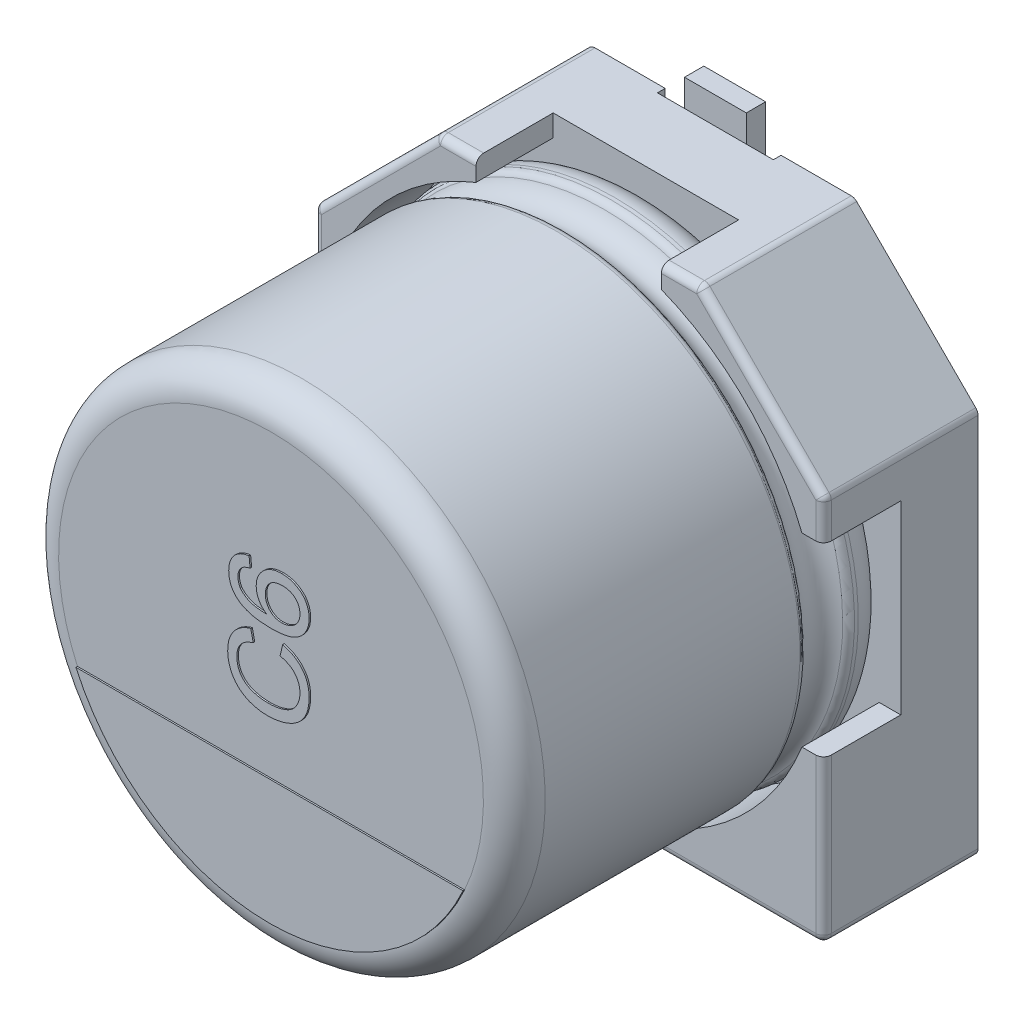
from build123d import *

# Parameters (mm, degrees)
BOSS_EXTRUDE1_DEPTH = 1
BOSS_EXTRUDE2_DEPTH = 1
SKETCH7_R           = 0.35
BOSS_EXTRUDE3_DEPTH = 0.15
SKETCH9_W           = 1.5
SKETCH9_H           = 2.35
CUT_EXTRUDE1_DEPTH  = 0.1
FILLET1_R           = 0.1
FILLET2_R           = 0.1
BOSS_EXTRUDE4_DEPTH = 0.02
TEXT_2_DEPTH        = 0.02
SKETCH19_W          = 0.8
SKETCH19_H          = 2.6
BOSS_EXTRUDE6_DEPTH = 0.25


with BuildPart() as part:
    # Sketch2 → Boss-Extrude1 (new body)
    with BuildSketch(Plane.XY):
        Polygon((-3.3, 1.7), (-1.7, 3.3), (1.7, 3.3), (3.3, 1.7), (3.3, -3.3), (-3.3, -3.3), align=None)
    extrude(amount=BOSS_EXTRUDE1_DEPTH)

    # Sketch4 → Boss-Extrude2 (add)
    with BuildSketch(Plane.XY.offset(1)):
        with BuildLine():
            Line((-3.3, 1.7), (-1.7, 3.3))
            Line((-1.7, 3.3), (-1.2, 3.3))
            Line((-1.2, 3.3), (-1.2, 3.020347662))
            ThreePointArc((-1.2, 3.020347662), (-2.298097039, 2.298097039), (-3.020347662, 1.2))
            Line((-3.020347662, 1.2), (-3.3, 1.2))
            Line((-3.3, 1.2), (-3.3, 1.7))
        make_face()
        with BuildLine():
            Line((1.7, 3.3), (3.3, 1.7))
            Line((3.3, 1.7), (3.3, 1.2))
            Line((3.3, 1.2), (3.020347662, 1.2))
            ThreePointArc((3.020347662, 1.2), (2.298097039, 2.298097039), (1.2, 3.020347662))
            Line((1.2, 3.020347662), (1.2, 3.3))
            Line((1.2, 3.3), (1.7, 3.3))
        make_face()
        with BuildLine():
            Line((3.3, -1.2), (3.3, -3.3))
            Line((3.3, -3.3), (1.2, -3.3))
            Line((1.2, -3.3), (1.2, -3.020347662))
            ThreePointArc((1.2, -3.020347662), (2.298097039, -2.298097039), (3.020347662, -1.2))
            Line((3.020347662, -1.2), (3.3, -1.2))
        make_face()
        with BuildLine():
            Line((-3.3, -1.2), (-3.3, -3.3))
            Line((-3.3, -3.3), (-1.2, -3.3))
            Line((-1.2, -3.3), (-1.2, -3.020347662))
            ThreePointArc((-1.2, -3.020347662), (-2.298097039, -2.298097039), (-3.020347662, -1.2))
            Line((-3.020347662, -1.2), (-3.3, -1.2))
        make_face()
    extrude(amount=BOSS_EXTRUDE2_DEPTH)

    # Sketch7 → Boss-Extrude3 (add)
    with BuildSketch(Plane(origin=(0, 0, 0), x_dir=(1, 0, 0), z_dir=(0, 0, -1))):
        with Locations((-2.232271432, 1.911844843)):
            Circle(SKETCH7_R)
        with Locations((2.232271432, 1.911844843)):
            Circle(SKETCH7_R)
        with Locations((-2.232271432, -1.911844843)):
            Circle(SKETCH7_R)
        with Locations((2.232271432, -1.911844843)):
            Circle(SKETCH7_R)
    extrude(amount=BOSS_EXTRUDE3_DEPTH)

    # Sketch9 → Cut-Extrude1 (cut)
    with BuildSketch(Plane(origin=(0, 0, 0), x_dir=(1, 0, 0), z_dir=(0, 0, -1))):
        with Locations((0, 2.125)):
            Rectangle(SKETCH9_W, SKETCH9_H)
        with Locations((0, -2.125)):
            Rectangle(SKETCH9_W, SKETCH9_H)
    extrude(amount=-CUT_EXTRUDE1_DEPTH, mode=Mode.SUBTRACT)

    # Fillet1
    fillet1_edges = [part.edges().sort_by_distance(p)[0] for p in [
        (3.3, -3.3, 1),
        (-3.3, -3.3, 1),
        (-3.3, 1.7, 1),
        (-1.7, 3.3, 1),
        (1.7, 3.3, 1),
        (3.3, 1.7, 1),
    ]]
    fillet(fillet1_edges, radius=FILLET1_R)

    # Sketch10 → Revolve1 (revolve)
    with BuildSketch(Plane(origin=(0, 0, 0), x_dir=(0, 0, -1), z_dir=(1, 0, 0))):
        with BuildLine():
            Line((-5.853626625, 0), (-1, 0))
            Line((-1, 0), (-1, 2.75))
            ThreePointArc((-1, 2.75), (-1.117157288, 3.032842712), (-1.4, 3.15))
            Line((-1.4, 3.15), (-1.449422929, 3.15))
            ThreePointArc((-1.449422929, 3.15), (-1.504479696, 3.133479053), (-1.541344666, 3.089375046))
            ThreePointArc((-1.541344666, 3.089375046), (-1.801990181, 2.917472047), (-2.062635697, 3.089375046))
            ThreePointArc((-2.062635697, 3.089375046), (-2.099500666, 3.133479053), (-2.154557434, 3.15))
            Line((-2.154557434, 3.15), (-5.453626625, 3.15))
            ThreePointArc((-5.453626625, 3.15), (-5.736469337, 3.032842712), (-5.853626625, 2.75))
            Line((-5.853626625, 2.75), (-5.853626625, 0))
        make_face()
    revolve(axis=Axis((0, 0, -18.9630778), (0, 0, 1)))

    # Fillet2
    fillet2_edges = [part.edges().sort_by_distance(p)[0] for p in [
        (2.2, -3.3, 2),
        (3.270710678, -3.270710678, 2),
        (3.3, 1.429289322, 2),
        (3.292387953, 1.696846987, 2),
        (1.429289322, 3.3, 2),
        (1.696846987, 3.292387953, 2),
        (-1.429289322, 3.3, 2),
        (-1.696846987, 3.292387953, 2),
        (-2.5, 2.5, 2),
        (-3.292387953, 1.696846987, 2),
        (-3.3, -2.2, 2),
        (-3.270710678, -3.270710678, 2),
        (3.3, -2.2, 2),
        (2.5, 2.5, 2),
        (-3.3, 1.429289322, 2),
        (-2.2, -3.3, 2),
    ]]
    fillet(fillet2_edges, radius=FILLET2_R)

    # Sketch13 → Boss-Extrude4 (add)
    with BuildSketch(Plane.XY.offset(5.853626625)):
        with BuildLine():
            Line((-2.506238836, -1.131930607), (2.506238836, -1.131930607))
            ThreePointArc((2.506238836, -1.131930607), (0, -2.75), (-2.506238836, -1.131930607))
        make_face()
    extrude(amount=BOSS_EXTRUDE4_DEPTH)

    # Sketch15 → Text 2 (add)
    with BuildSketch(Plane.XY.offset(5.853626625)):
        with BuildLine():
            Line((0.137389622, 0.316593633), (0.171139963, 0.461473149))
            add(Edge.make_bspline(
                [(0.171139963, 0.461473149), (0.184719205, 0.457843617), (0.211281888, 0.450743802), (0.249294555, 0.436704736), (0.284973396, 0.420954535), (0.318198658, 0.403080099), (0.348825876, 0.383025378), (0.37700883, 0.360877976), (0.402792333, 0.336641169), (0.425858287, 0.31012897), (0.446489175, 0.282031663), (0.464171898, 0.252152583), (0.479591278, 0.221021834), (0.491950748, 0.188130242), (0.501325327, 0.153719305), (0.508136304, 0.117874786), (0.512336792, 0.080509598), (0.512889354, 0.055039538), (0.513170865, 0.042063415)],
                knots=[0, 0, 0, 0, 1.145367768, 2.240481511, 3.299486216, 4.322926322, 5.312543435, 6.280301985, 7.2416403, 8.192823262, 9.141388579, 10.079393599, 11.019812878, 11.970222822, 12.938950422, 13.923894909, 14.942295558, 16, 16, 16, 16], degree=3))
            add(Edge.make_bspline(
                [(0.513170865, 0.042063415), (0.512974968, 0.028750287), (0.512591712, 0.002704216), (0.509548347, -0.035461334), (0.50408886, -0.071710574), (0.497105361, -0.106172698), (0.487517876, -0.138603304), (0.476080502, -0.169237106), (0.462232577, -0.197809744), (0.446522059, -0.224623591), (0.428664346, -0.249552903), (0.409152567, -0.273167676), (0.387446592, -0.294893809), (0.364059715, -0.315274756), (0.338683214, -0.333866555), (0.311661899, -0.351353217), (0.282519639, -0.366881226), (0.251796737, -0.381026037), (0.219790643, -0.393441241), (0.187133568, -0.404424353), (0.153760439, -0.413403647), (0.119952084, -0.421134241), (0.085424029, -0.426750142), (0.050435341, -0.431208994), (0.014771509, -0.433660561), (-0.009201459, -0.433983161), (-0.021278143, -0.434145675)],
                knots=[0, 0, 0, 0, 1.180680974, 2.309907975, 3.39230657, 4.430402719, 5.425739985, 6.38846843, 7.327253855, 8.238163682, 9.141319901, 10.044148192, 10.951882972, 11.861898394, 12.79276478, 13.739539846, 14.714057202, 15.718574761, 16.737652364, 17.7573291, 18.772768038, 19.801551793, 20.831755737, 21.873891013, 22.928945814, 24, 24, 24, 24], degree=3))
            add(Edge.make_bspline(
                [(-0.021278143, -0.434145675), (-0.034315397, -0.4339132), (-0.060073717, -0.433453889), (-0.098081116, -0.430862244), (-0.134761949, -0.426098769), (-0.17014477, -0.419495443), (-0.204305873, -0.411082573), (-0.23725329, -0.400840529), (-0.268852986, -0.388622281), (-0.299113504, -0.374745627), (-0.327665253, -0.358785546), (-0.354762577, -0.3416054), (-0.379878011, -0.322520006), (-0.403474105, -0.302187934), (-0.425149261, -0.280085417), (-0.444954877, -0.256284136), (-0.463070995, -0.230988325), (-0.479329594, -0.204201975), (-0.493595656, -0.176275134), (-0.506302564, -0.147622628), (-0.516717602, -0.118130488), (-0.525377287, -0.088032537), (-0.532271201, -0.057263976), (-0.536881183, -0.025752912), (-0.539885404, 0.006471539), (-0.540292549, 0.02819978), (-0.540498339, 0.039182288)],
                knots=[0, 0, 0, 0, 1.185610122, 2.34246615, 3.46204209, 4.547238403, 5.613845268, 6.659506797, 7.682407252, 8.692734231, 9.683951048, 10.654680354, 11.607833779, 12.549673105, 13.484816388, 14.419272854, 15.362680812, 16.31159957, 17.265732262, 18.21261905, 19.159670199, 20.10733745, 21.059306249, 22.024427552, 23.00144979, 24, 24, 24, 24], degree=3))
            add(Edge.make_bspline(
                [(-0.540498339, 0.039182288), (-0.54027585, 0.051472155), (-0.539838527, 0.075629106), (-0.53596558, 0.111030265), (-0.53016218, 0.145076857), (-0.521400985, 0.17750367), (-0.510653256, 0.208616176), (-0.496791219, 0.237924274), (-0.481084534, 0.266024209), (-0.462639265, 0.292395393), (-0.442059798, 0.317116672), (-0.419396701, 0.339965227), (-0.394799964, 0.360899322), (-0.368077184, 0.379659831), (-0.339408707, 0.396504218), (-0.308850674, 0.411613497), (-0.276208278, 0.424627676), (-0.253468798, 0.431587541), (-0.241890133, 0.435131419)],
                knots=[0, 0, 0, 0, 1.098215313, 2.158650937, 3.179873416, 4.182349117, 5.157851008, 6.118027029, 7.076341197, 8.032298369, 8.990121974, 9.948357669, 10.905435138, 11.873450097, 12.863034414, 13.874936208, 14.917943528, 16, 16, 16, 16], degree=3))
            Line((-0.241890133, 0.435131419), (-0.210815123, 0.290251903))
            add(Edge.make_bspline(
                [(-0.210815123, 0.290251903), (-0.21970095, 0.287406696), (-0.237093262, 0.281837744), (-0.261880399, 0.271949526), (-0.284890959, 0.26127058), (-0.305968529, 0.249546525), (-0.325118157, 0.236751953), (-0.342572578, 0.223181488), (-0.358006003, 0.208509995), (-0.371774287, 0.193035906), (-0.383503548, 0.176359634), (-0.393897604, 0.158872143), (-0.402497099, 0.140204709), (-0.409770496, 0.120625878), (-0.415306335, 0.099952647), (-0.419201016, 0.078269202), (-0.421455067, 0.05555649), (-0.421789822, 0.040079052), (-0.421960554, 0.032185266)],
                knots=[0, 0, 0, 0, 1.235697765, 2.418642872, 3.532555292, 4.594392283, 5.610119701, 6.580908344, 7.519430642, 8.427315627, 9.319973334, 10.216139639, 11.118687699, 12.038725643, 12.980015607, 13.949697744, 14.954307006, 16, 16, 16, 16], degree=3))
            add(Edge.make_bspline(
                [(-0.421960554, 0.032185266), (-0.42182894, 0.023122531), (-0.421570094, 0.005298806), (-0.418741414, -0.020887312), (-0.414566199, -0.046031584), (-0.408336958, -0.06996279), (-0.400471327, -0.092727501), (-0.391074044, -0.1144289), (-0.379637086, -0.134923416), (-0.366527285, -0.154190234), (-0.351810113, -0.172119905), (-0.335998775, -0.188775555), (-0.319056253, -0.204115277), (-0.300881808, -0.217955028), (-0.281409051, -0.230297385), (-0.260823414, -0.241466755), (-0.238987177, -0.251110914), (-0.208358467, -0.262011565), (-0.168833348, -0.2727293), (-0.120495718, -0.282252213), (-0.071437696, -0.288256875), (-0.038444502, -0.28892902), (-0.021895528, -0.289266159)],
                knots=[0, 0, 0, 0, 0.935100075, 1.839065892, 2.715632844, 3.564034634, 4.388093667, 5.199800233, 6.00171917, 6.806945003, 7.602082793, 8.393428172, 9.17553264, 9.958694158, 10.748327009, 11.553054559, 12.374096334, 13.209545573, 14.906836637, 16.595465087, 18.292327764, 20, 20, 20, 20], degree=3))
            add(Edge.make_bspline(
                [(-0.021895528, -0.289266159), (-0.001088295, -0.28888169), (0.039347759, -0.288134525), (0.097860474, -0.280941105), (0.152411861, -0.269796756), (0.194923463, -0.256480088), (0.226325575, -0.243084208), (0.248317261, -0.232252213), (0.268667217, -0.219887416), (0.287491124, -0.206297945), (0.304734045, -0.191308606), (0.320487583, -0.175128268), (0.334903322, -0.157753307), (0.347306436, -0.138977849), (0.35831932, -0.119524584), (0.368112186, -0.099638997), (0.376394559, -0.079308568), (0.382828475, -0.058451271), (0.388388272, -0.03736), (0.392020193, -0.015802455), (0.394069935, 0.006215216), (0.39444386, 0.020999538), (0.39463308, 0.02848096)],
                knots=[0, 0, 0, 0, 2.106854985, 4.094388766, 5.961441423, 7.741458329, 8.594569961, 9.418076185, 10.222480919, 11.003619353, 11.767127393, 12.533696482, 13.289066307, 14.050325982, 14.809648647, 15.552384038, 16.294338903, 17.030544626, 17.761979889, 18.502240791, 19.242077596, 20, 20, 20, 20], degree=3))
            add(Edge.make_bspline(
                [(0.39463308, 0.02848096), (0.39444584, 0.037409013), (0.394075974, 0.055045074), (0.390838523, 0.080901779), (0.386067714, 0.105827286), (0.378705874, 0.129519626), (0.369692165, 0.152297488), (0.358576684, 0.173974247), (0.345208005, 0.194481731), (0.330029126, 0.214061155), (0.312758155, 0.232351457), (0.293534236, 0.249113535), (0.27226973, 0.264151013), (0.249305901, 0.278094539), (0.223956735, 0.289809664), (0.196977778, 0.300660635), (0.167925608, 0.309702449), (0.147714502, 0.314263574), (0.137389622, 0.316593633)],
                knots=[0, 0, 0, 0, 1.013374089, 2.001772144, 2.95501459, 3.891367103, 4.814208647, 5.733921849, 6.652182523, 7.590185968, 8.54346024, 9.504121027, 10.481158517, 11.497760682, 12.549996529, 13.647863555, 14.798406869, 16, 16, 16, 16], degree=3))
        make_face()
        with BuildLine():
            Line((-0.263910173, 1.238554187), (-0.250739308, 1.106845536))
            add(Edge.make_bspline(
                [(-0.250739308, 1.106845536), (-0.262066955, 1.104003369), (-0.283389506, 1.098653428), (-0.31231033, 1.087434651), (-0.336772429, 1.075071798), (-0.349944593, 1.064331166), (-0.356106228, 1.059306945)],
                knots=[0, 0, 0, 0, 1.199207122, 2.257322842, 3.184815751, 4, 4, 4, 4], degree=3))
            add(Edge.make_bspline(
                [(-0.356106228, 1.059306945), (-0.360308802, 1.054994236), (-0.368574291, 1.046512136), (-0.379348416, 1.032587615), (-0.388476794, 1.017908865), (-0.395872165, 1.00243152), (-0.401714084, 0.986239198), (-0.405800816, 0.969264824), (-0.408330736, 0.951546855), (-0.408635402, 0.939474271), (-0.408789689, 0.933360548)],
                knots=[0, 0, 0, 0, 1.028360939, 2.022547923, 3.001693811, 3.976902288, 4.948369586, 5.937776631, 6.955661634, 8, 8, 8, 8], degree=3))
            add(Edge.make_bspline(
                [(-0.408789689, 0.933360548), (-0.408470554, 0.923449151), (-0.407839958, 0.903864664), (-0.401666469, 0.875130722), (-0.392426858, 0.847221986), (-0.383060608, 0.829931493), (-0.378332063, 0.8212024)],
                knots=[0, 0, 0, 0, 1.010336883, 1.996381556, 2.988474728, 4, 4, 4, 4], degree=3))
            add(Edge.make_bspline(
                [(-0.378332063, 0.8212024), (-0.371220994, 0.812615832), (-0.35662367, 0.794989661), (-0.329665846, 0.77206344), (-0.298406295, 0.751381043), (-0.269070379, 0.736194503), (-0.242664987, 0.7256364), (-0.220084591, 0.718679246), (-0.195186335, 0.71279144), (-0.167978967, 0.707874614), (-0.138433528, 0.704075164), (-0.106533319, 0.700898509), (-0.072196841, 0.699141789), (-0.048513373, 0.69875049), (-0.036301161, 0.69854872)],
                knots=[0, 0, 0, 0, 1.063250814, 2.182599524, 3.36380985, 4.638540699, 5.329632219, 6.077757597, 6.893023137, 7.772089793, 8.717285182, 9.73761699, 10.83341823, 12, 12, 12, 12], degree=3))
            add(Edge.make_bspline(
                [(-0.036301161, 0.69854872), (-0.047211061, 0.706313772), (-0.068567854, 0.721514335), (-0.096501329, 0.74833009), (-0.120124585, 0.77760857), (-0.138947726, 0.809396623), (-0.153668192, 0.842795113), (-0.163762394, 0.877283311), (-0.170639914, 0.912440761), (-0.171354352, 0.936208952), (-0.171714118, 0.948177771)],
                knots=[0, 0, 0, 0, 1.084001636, 2.121999332, 3.126469213, 4.123683166, 5.106931922, 6.075998312, 7.03114091, 8, 8, 8, 8], degree=3))
            add(Edge.make_bspline(
                [(-0.171714118, 0.948177771), (-0.171436912, 0.958480828), (-0.170889239, 0.978836477), (-0.166549178, 1.008812469), (-0.158958131, 1.037550632), (-0.149068989, 1.065299905), (-0.13556661, 1.091527432), (-0.119785478, 1.116871804), (-0.100584882, 1.140751828), (-0.078998478, 1.1634471), (-0.055003426, 1.184214016), (-0.029048993, 1.202305372), (-0.001458965, 1.217752742), (0.027936119, 1.230034553), (0.059003446, 1.239766995), (0.091724958, 1.24671395), (0.126168435, 1.250895647), (0.149656836, 1.251444342), (0.161673404, 1.251725052)],
                knots=[0, 0, 0, 0, 0.981582189, 1.939302258, 2.87789191, 3.810544529, 4.740168451, 5.683209003, 6.65100384, 7.654285831, 8.664634098, 9.669256765, 10.664156186, 11.671836555, 12.699357328, 13.762200315, 14.855150938, 16, 16, 16, 16], degree=3))
            add(Edge.make_bspline(
                [(0.161673404, 1.251725052), (0.177551784, 1.251205655), (0.208955034, 1.250178424), (0.255125626, 1.242147114), (0.299579783, 1.22895578), (0.334753634, 1.213359264), (0.361740804, 1.198980582), (0.380617593, 1.186774631), (0.398356819, 1.173722225), (0.415202853, 1.160071554), (0.430384613, 1.144832272), (0.444617472, 1.128928337), (0.457409357, 1.111834045), (0.469185898, 1.094052164), (0.479397361, 1.07524678), (0.488471349, 1.055965078), (0.496200717, 1.036048336), (0.502269576, 1.015432243), (0.507290467, 0.994222385), (0.510742792, 0.972348167), (0.512871929, 0.949867156), (0.513070448, 0.934668725), (0.513170865, 0.92698091)],
                knots=[0, 0, 0, 0, 1.777960384, 3.516337103, 5.232817765, 6.960340972, 7.816514579, 8.656393217, 9.475627613, 10.283429005, 11.082224935, 11.882498067, 12.672484914, 13.471761235, 14.269669532, 15.067244712, 15.857866702, 16.660166545, 17.47288749, 18.29786845, 19.139011754, 20, 20, 20, 20], degree=3))
            add(Edge.make_bspline(
                [(0.513170865, 0.92698091), (0.512810832, 0.91399763), (0.512104743, 0.888535135), (0.506680251, 0.851267049), (0.497615162, 0.815879371), (0.484941143, 0.782296826), (0.468940454, 0.750417112), (0.448882488, 0.720554395), (0.425361994, 0.692543437), (0.398242561, 0.666362643), (0.366927773, 0.642624541), (0.3307809, 0.62233689), (0.290118349, 0.605050009), (0.244828247, 0.590902203), (0.194863231, 0.580196397), (0.14033061, 0.572487765), (0.081222574, 0.567747043), (0.040263709, 0.567149461), (0.019057631, 0.566840069)],
                knots=[0, 0, 0, 0, 0.898506621, 1.76212948, 2.600594211, 3.422599815, 4.24233914, 5.064166416, 5.906856258, 6.769969817, 7.668413694, 8.619051846, 9.63165591, 10.722000005, 11.898403521, 13.164960021, 14.532183992, 16, 16, 16, 16], degree=3))
            add(Edge.make_bspline(
                [(0.019057631, 0.566840069), (0.006982207, 0.566891371), (-0.016834658, 0.566992555), (-0.051887147, 0.568618495), (-0.085738797, 0.57048365), (-0.118254557, 0.573679297), (-0.149580671, 0.577452518), (-0.179532919, 0.582516131), (-0.208344113, 0.587953841), (-0.235787414, 0.594564986), (-0.262120992, 0.601934797), (-0.287055498, 0.610417706), (-0.310913542, 0.619377759), (-0.333318762, 0.629542753), (-0.354636063, 0.640376269), (-0.374470963, 0.652351134), (-0.393276992, 0.664909515), (-0.40487338, 0.674180633), (-0.410641841, 0.678792422)],
                knots=[0, 0, 0, 0, 1.28053818, 2.525659045, 3.721026795, 4.875695215, 5.990149104, 7.066600796, 8.096771069, 9.099076143, 10.059445332, 10.995815448, 11.891625124, 12.761078582, 13.603822678, 14.426062074, 15.217066536, 16, 16, 16, 16], degree=3))
            add(Edge.make_bspline(
                [(-0.410641841, 0.678792422), (-0.419973797, 0.687088947), (-0.438367949, 0.703442167), (-0.462128836, 0.731417386), (-0.482424289, 0.761227338), (-0.498821258, 0.793347456), (-0.511604862, 0.827532245), (-0.520884625, 0.863803134), (-0.526266247, 0.902261337), (-0.526967998, 0.928541676), (-0.527327474, 0.942003928)],
                knots=[0, 0, 0, 0, 1.005002357, 1.980952959, 2.948226316, 3.90482984, 4.879026092, 5.883055346, 6.915583142, 8, 8, 8, 8], degree=3))
            add(Edge.make_bspline(
                [(-0.527327474, 0.942003928), (-0.527150278, 0.95202807), (-0.526802163, 0.971721303), (-0.523461959, 1.000576916), (-0.517879309, 1.028023674), (-0.510348939, 1.054122709), (-0.500325055, 1.078722262), (-0.488445667, 1.102105936), (-0.47415551, 1.124036289), (-0.457649818, 1.144354556), (-0.439396485, 1.163111065), (-0.419242227, 1.179911009), (-0.397438235, 1.194691087), (-0.373939162, 1.207566881), (-0.348856244, 1.218423335), (-0.32208168, 1.227337023), (-0.293622348, 1.234112021), (-0.273951515, 1.23705294), (-0.263910173, 1.238554187)],
                knots=[0, 0, 0, 0, 1.095988384, 2.15315746, 3.171326302, 4.156539379, 5.119213808, 6.072133135, 7.021027441, 7.975952916, 8.930907862, 9.879001051, 10.840359051, 11.807350428, 12.805278655, 13.825435679, 14.889953203, 16, 16, 16, 16], degree=3))
        make_face()
        with BuildLine():
            add(Edge.make_bspline(
                [(0.158998072, 0.69854872), (0.169310164, 0.698917067), (0.189798968, 0.699648927), (0.220157625, 0.705174824), (0.249735881, 0.714350586), (0.278297889, 0.726747423), (0.304884941, 0.742215847), (0.328595717, 0.76036263), (0.348808335, 0.781137978), (0.365426018, 0.804404293), (0.378336608, 0.829852747), (0.38802361, 0.857119824), (0.393612374, 0.88641755), (0.394287705, 0.906583702), (0.39463308, 0.916896967)],
                knots=[0, 0, 0, 0, 1.034371533, 2.055163721, 3.085036369, 4.136219926, 5.172765015, 6.164074703, 7.123048089, 8.070464312, 9.021723619, 9.977430468, 10.965628467, 12, 12, 12, 12], degree=3))
            add(Edge.make_bspline(
                [(0.39463308, 0.916896967), (0.394434279, 0.924247718), (0.394046237, 0.938595735), (0.391039304, 0.959603562), (0.386415535, 0.97964735), (0.379583948, 0.998611041), (0.370864964, 1.016468898), (0.360253388, 1.033313644), (0.347717449, 1.049134388), (0.33328016, 1.063739843), (0.317223299, 1.076940014), (0.2996454, 1.088409212), (0.280835665, 1.098537586), (0.260331852, 1.10615574), (0.238659248, 1.112363432), (0.215612932, 1.116927272), (0.191166443, 1.119606726), (0.174370852, 1.119877865), (0.165789299, 1.120016401)],
                knots=[0, 0, 0, 0, 1.023436885, 1.997658284, 2.950132304, 3.883974581, 4.798406504, 5.712938251, 6.651509614, 7.604127386, 8.56812849, 9.540661787, 10.523651728, 11.536824179, 12.580180944, 13.661349568, 14.805088061, 16, 16, 16, 16], degree=3))
            add(Edge.make_bspline(
                [(0.165789299, 1.120016401), (0.157548441, 1.119888187), (0.141432403, 1.119637449), (0.117917662, 1.116806175), (0.095680484, 1.112701039), (0.074880784, 1.106311511), (0.055300216, 1.09871455), (0.037270196, 1.088824301), (0.020427558, 1.077498159), (0.005087373, 1.064330767), (-0.00877089, 1.049801972), (-0.020533854, 1.033720697), (-0.030711117, 1.016607851), (-0.038997353, 0.998108203), (-0.045364198, 0.978290394), (-0.049772296, 0.957176687), (-0.052850552, 0.934891145), (-0.053066074, 0.919583346), (-0.053176332, 0.911752098)],
                knots=[0, 0, 0, 0, 1.155514215, 2.259753865, 3.318605965, 4.323374797, 5.308078351, 6.25972982, 7.201991692, 8.150865321, 9.090370884, 10.012362416, 10.939962465, 11.879024295, 12.84989812, 13.854113716, 14.902195686, 16, 16, 16, 16], degree=3))
            add(Edge.make_bspline(
                [(-0.053176332, 0.911752098), (-0.053062563, 0.904469026), (-0.05283837, 0.890117041), (-0.049736111, 0.869070021), (-0.04531916, 0.848783861), (-0.03888687, 0.829344748), (-0.030625647, 0.810726817), (-0.020514143, 0.793040359), (-0.008629831, 0.77612924), (0.005026041, 0.76029047), (0.020125409, 0.745658398), (0.036657323, 0.733050313), (0.05435757, 0.722564717), (0.072922127, 0.713543606), (0.092831288, 0.706750937), (0.113895406, 0.702121891), (0.136070496, 0.69914117), (0.151236642, 0.698749276), (0.158998072, 0.69854872)],
                knots=[0, 0, 0, 0, 1.036834006, 2.043179957, 3.024920909, 3.992398523, 4.95507473, 5.922552344, 6.890671636, 7.895735102, 8.898133371, 9.881478754, 10.850387221, 11.825341133, 12.817584876, 13.839615819, 14.894401237, 16, 16, 16, 16], degree=3))
        make_face(mode=Mode.SUBTRACT)
    extrude(amount=TEXT_2_DEPTH)

    # Sketch19 → Boss-Extrude6 (add)
    with BuildSketch(Plane(origin=(0, 0, 0.1), x_dir=(1, 0, 0), z_dir=(0, 0, -1))):
        with Locations((0, 2.35)):
            Rectangle(SKETCH19_W, SKETCH19_H)
        with Locations((0, -2.35)):
            Rectangle(SKETCH19_W, SKETCH19_H)
    extrude(amount=BOSS_EXTRUDE6_DEPTH)


solid = part.part
